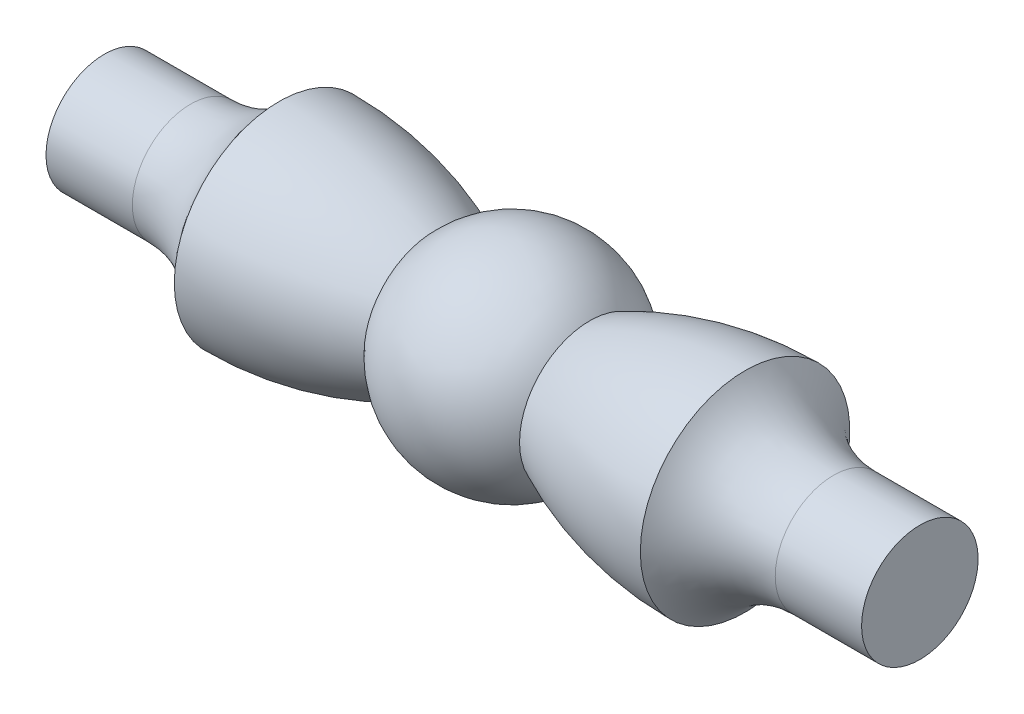
from build123d import *


with BuildPart() as part:
    # Esquisse1 → Révolution1 (revolve)
    with BuildSketch(Plane.XY):
        with BuildLine():
            Line((-7, 0), (-7, 1))
            Line((-7, 1), (-5.51771325, 1))
            ThreePointArc((-5.51771325, 1), (-4.660362956, 1.211647907), (-4, 1.79796278))
            ThreePointArc((-4, 1.79796278), (-2.634488917, 1.648039478), (-1.334035601, 1.205412449))
            ThreePointArc((-1.334035601, 1.205412449), (0, 1.79796278), (1.334035601, 1.205412449))
            ThreePointArc((1.334035601, 1.205412449), (2.634488917, 1.648039478), (4, 1.79796278))
            ThreePointArc((4, 1.79796278), (4.660362956, 1.211647907), (5.51771325, 1))
            Line((5.51771325, 1), (7, 1))
            Line((7, 1), (7, 0))
            Line((7, 0), (-7, 0))
        make_face()
    revolve(axis=Axis((-7, 0, 0), (1, 0, 0)))


solid = part.part
